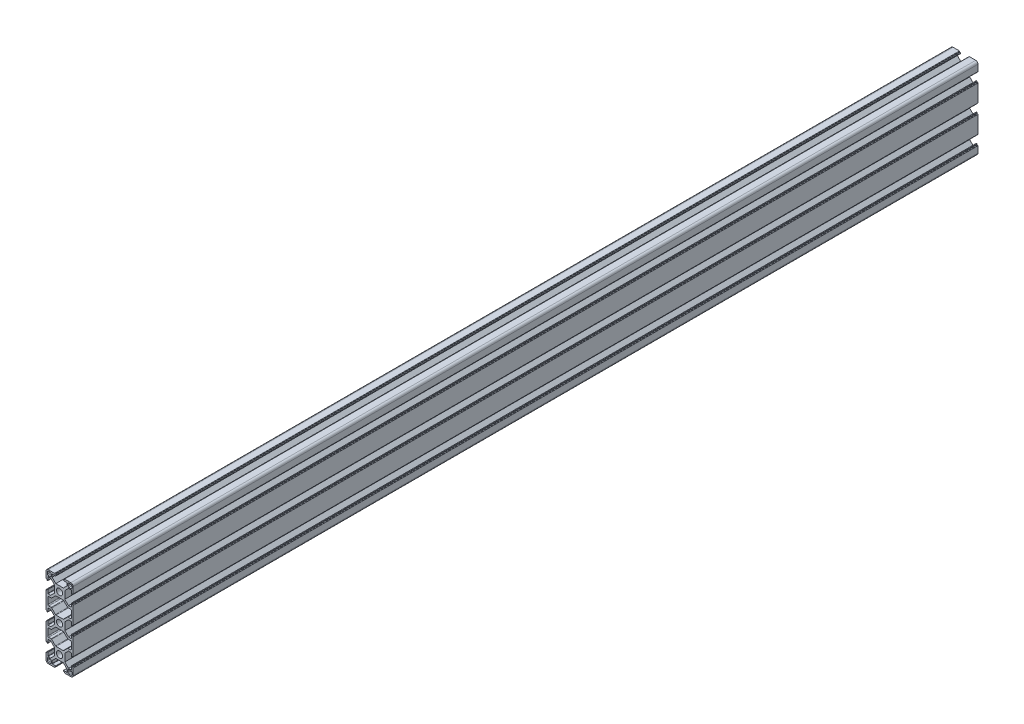
from build123d import *

# Parameters (mm, degrees)
SKETCH_1_R      = 3.4
EXTRUDE_1_DEPTH = 1000


with BuildPart() as part:
    # Эскиз1 → Бобышка-Вытянуть1 (new body)
    with BuildSketch(Plane.XY):
        with BuildLine():
            Line((-15, 8.25), (-15, 12.5))
            ThreePointArc((-15, 12.5), (-14.267766953, 14.267766953), (-12.5, 15))
            Line((-12.5, 15), (-8.25, 15))
            Line((-8.25, 15), (-5.5, 15))
            ThreePointArc((-5.5, 15), (-5.287867966, 14.912132034), (-5.2, 14.7))
            Line((-5.2, 14.7), (-5.2, 14.3))
            ThreePointArc((-5.2, 14.3), (-5.112132034, 14.087867966), (-4.9, 14))
            Line((-4.9, 14), (-4.4, 14))
            ThreePointArc((-4.4, 14), (-4.187867966, 13.912132034), (-4.1, 13.7))
            Line((-4.1, 13.7), (-4.1, 13.3))
            ThreePointArc((-4.1, 13.3), (-4.187867966, 13.087867966), (-4.4, 13))
            Line((-4.4, 13), (-7.95, 13))
            ThreePointArc((-7.95, 13), (-8.162132034, 12.912132034), (-8.25, 12.7))
            Line((-8.25, 12.7), (-8.25, 9.85))
            Line((-8.25, 9.85), (-4.2, 5.8))
            Line((-4.2, 5.8), (4.2, 5.8))
            Line((4.2, 5.8), (8.25, 9.85))
            Line((8.25, 9.85), (8.25, 12.7))
            ThreePointArc((8.25, 12.7), (8.162132034, 12.912132034), (7.95, 13))
            Line((7.95, 13), (4.4, 13))
            ThreePointArc((4.4, 13), (4.187867966, 13.087867966), (4.1, 13.3))
            Line((4.1, 13.3), (4.1, 13.7))
            ThreePointArc((4.1, 13.7), (4.187867966, 13.912132034), (4.4, 14))
            Line((4.4, 14), (4.9, 14))
            ThreePointArc((4.9, 14), (5.112132034, 14.087867966), (5.2, 14.3))
            Line((5.2, 14.3), (5.2, 14.7))
            ThreePointArc((5.2, 14.7), (5.287867966, 14.912132034), (5.5, 15))
            Line((5.5, 15), (8.25, 15))
            Line((8.25, 15), (12.5, 15))
            ThreePointArc((12.5, 15), (14.267766953, 14.267766953), (15, 12.5))
            Line((15, 12.5), (15, 8.25))
            Line((15, 8.25), (15, 5.5))
            ThreePointArc((15, 5.5), (14.912132034, 5.287867966), (14.7, 5.2))
            Line((14.7, 5.2), (14.3, 5.2))
            ThreePointArc((14.3, 5.2), (14.087867966, 5.112132034), (14, 4.9))
            Line((14, 4.9), (14, 4.4))
            ThreePointArc((14, 4.4), (13.912132034, 4.187867966), (13.7, 4.1))
            Line((13.7, 4.1), (13.3, 4.1))
            ThreePointArc((13.3, 4.1), (13.087867966, 4.187867966), (13, 4.4))
            Line((13, 4.4), (13, 7.95))
            ThreePointArc((13, 7.95), (12.912132034, 8.162132034), (12.7, 8.25))
            Line((12.7, 8.25), (9.85, 8.25))
            Line((9.85, 8.25), (5.8, 4.2))
            Line((5.8, 4.2), (5.8, -4.2))
            Line((5.8, -4.2), (9.85, -8.25))
            Line((9.85, -8.25), (12.7, -8.25))
            ThreePointArc((12.7, -8.25), (12.912132034, -8.162132034), (13, -7.95))
            Line((13, -7.95), (13, -4.4))
            ThreePointArc((13, -4.4), (13.087867966, -4.187867966), (13.3, -4.1))
            Line((13.3, -4.1), (13.7, -4.1))
            ThreePointArc((13.7, -4.1), (13.912132034, -4.187867966), (14, -4.4))
            Line((14, -4.4), (14, -4.9))
            ThreePointArc((14, -4.9), (14.087867966, -5.112132034), (14.3, -5.2))
            Line((14.3, -5.2), (14.7, -5.2))
            ThreePointArc((14.7, -5.2), (14.912132034, -5.287867966), (15, -5.5))
            Line((15, -5.5), (15, -8.25))
            Line((15, -8.25), (15, -21.75))
            Line((15, -21.75), (15, -24.5))
            ThreePointArc((15, -24.5), (14.912132034, -24.712132034), (14.7, -24.8))
            Line((14.7, -24.8), (14.3, -24.8))
            ThreePointArc((14.3, -24.8), (14.087867966, -24.887867966), (14, -25.1))
            Line((14, -25.1), (14, -25.6))
            ThreePointArc((14, -25.6), (13.912132034, -25.812132034), (13.7, -25.9))
            Line((13.7, -25.9), (13.3, -25.9))
            ThreePointArc((13.3, -25.9), (13.087867966, -25.812132034), (13, -25.6))
            Line((13, -25.6), (13, -22.05))
            ThreePointArc((13, -22.05), (12.912132034, -21.837867966), (12.7, -21.75))
            Line((12.7, -21.75), (9.85, -21.75))
            Line((9.85, -21.75), (5.8, -25.8))
            Line((5.8, -25.8), (5.8, -34.2))
            Line((5.8, -34.2), (9.85, -38.25))
            Line((9.85, -38.25), (12.7, -38.25))
            ThreePointArc((12.7, -38.25), (12.912132034, -38.162132034), (13, -37.95))
            Line((13, -37.95), (13, -34.4))
            ThreePointArc((13, -34.4), (13.087867966, -34.187867966), (13.3, -34.1))
            Line((13.3, -34.1), (13.7, -34.1))
            ThreePointArc((13.7, -34.1), (13.912132034, -34.187867966), (14, -34.4))
            Line((14, -34.4), (14, -34.9))
            ThreePointArc((14, -34.9), (14.087867966, -35.112132034), (14.3, -35.2))
            Line((14.3, -35.2), (14.7, -35.2))
            ThreePointArc((14.7, -35.2), (14.912132034, -35.287867966), (15, -35.5))
            Line((15, -35.5), (15, -38.25))
            Line((15, -38.25), (15, -51.75))
            Line((15, -51.75), (15, -54.5))
            ThreePointArc((15, -54.5), (14.912132034, -54.712132034), (14.7, -54.8))
            Line((14.7, -54.8), (14.3, -54.8))
            ThreePointArc((14.3, -54.8), (14.087867966, -54.887867966), (14, -55.1))
            Line((14, -55.1), (14, -55.6))
            ThreePointArc((14, -55.6), (13.912132034, -55.812132034), (13.7, -55.9))
            Line((13.7, -55.9), (13.3, -55.9))
            ThreePointArc((13.3, -55.9), (13.087867966, -55.812132034), (13, -55.6))
            Line((13, -55.6), (13, -52.05))
            ThreePointArc((13, -52.05), (12.912132034, -51.837867966), (12.7, -51.75))
            Line((12.7, -51.75), (9.85, -51.75))
            Line((9.85, -51.75), (5.8, -55.8))
            Line((5.8, -55.8), (5.8, -64.2))
            Line((5.8, -64.2), (9.85, -68.25))
            Line((9.85, -68.25), (12.7, -68.25))
            ThreePointArc((12.7, -68.25), (12.912132034, -68.162132034), (13, -67.95))
            Line((13, -67.95), (13, -64.4))
            ThreePointArc((13, -64.4), (13.087867966, -64.187867966), (13.3, -64.1))
            Line((13.3, -64.1), (13.7, -64.1))
            ThreePointArc((13.7, -64.1), (13.912132034, -64.187867966), (14, -64.4))
            Line((14, -64.4), (14, -64.9))
            ThreePointArc((14, -64.9), (14.087867966, -65.112132034), (14.3, -65.2))
            Line((14.3, -65.2), (14.7, -65.2))
            ThreePointArc((14.7, -65.2), (14.912132034, -65.287867966), (15, -65.5))
            Line((15, -65.5), (15, -68.25))
            Line((15, -68.25), (15, -72.5))
            ThreePointArc((15, -72.5), (14.267766953, -74.267766953), (12.5, -75))
            Line((12.5, -75), (8.25, -75))
            Line((8.25, -75), (5.5, -75))
            ThreePointArc((5.5, -75), (5.287867966, -74.912132034), (5.2, -74.7))
            Line((5.2, -74.7), (5.2, -74.3))
            ThreePointArc((5.2, -74.3), (5.112132034, -74.087867966), (4.9, -74))
            Line((4.9, -74), (4.4, -74))
            ThreePointArc((4.4, -74), (4.187867966, -73.912132034), (4.1, -73.7))
            Line((4.1, -73.7), (4.1, -73.3))
            ThreePointArc((4.1, -73.3), (4.187867966, -73.087867966), (4.4, -73))
            Line((4.4, -73), (7.95, -73))
            ThreePointArc((7.95, -73), (8.162132034, -72.912132034), (8.25, -72.7))
            Line((8.25, -72.7), (8.25, -69.85))
            Line((8.25, -69.85), (4.2, -65.8))
            Line((4.2, -65.8), (-4.2, -65.8))
            Line((-4.2, -65.8), (-8.25, -69.85))
            Line((-8.25, -69.85), (-8.25, -72.7))
            ThreePointArc((-8.25, -72.7), (-8.162132034, -72.912132034), (-7.95, -73))
            Line((-7.95, -73), (-4.4, -73))
            ThreePointArc((-4.4, -73), (-4.187867966, -73.087867966), (-4.1, -73.3))
            Line((-4.1, -73.3), (-4.1, -73.7))
            ThreePointArc((-4.1, -73.7), (-4.187867966, -73.912132034), (-4.4, -74))
            Line((-4.4, -74), (-4.9, -74))
            ThreePointArc((-4.9, -74), (-5.112132034, -74.087867966), (-5.2, -74.3))
            Line((-5.2, -74.3), (-5.2, -74.7))
            ThreePointArc((-5.2, -74.7), (-5.287867966, -74.912132034), (-5.5, -75))
            Line((-5.5, -75), (-8.25, -75))
            Line((-8.25, -75), (-12.5, -75))
            ThreePointArc((-12.5, -75), (-14.267766953, -74.267766953), (-15, -72.5))
            Line((-15, -72.5), (-15, -68.25))
            Line((-15, -68.25), (-15, -65.5))
            ThreePointArc((-15, -65.5), (-14.912132034, -65.287867966), (-14.7, -65.2))
            Line((-14.7, -65.2), (-14.3, -65.2))
            ThreePointArc((-14.3, -65.2), (-14.087867966, -65.112132034), (-14, -64.9))
            Line((-14, -64.9), (-14, -64.4))
            ThreePointArc((-14, -64.4), (-13.912132034, -64.187867966), (-13.7, -64.1))
            Line((-13.7, -64.1), (-13.3, -64.1))
            ThreePointArc((-13.3, -64.1), (-13.087867966, -64.187867966), (-13, -64.4))
            Line((-13, -64.4), (-13, -67.95))
            ThreePointArc((-13, -67.95), (-12.912132034, -68.162132034), (-12.7, -68.25))
            Line((-12.7, -68.25), (-9.85, -68.25))
            Line((-9.85, -68.25), (-5.8, -64.2))
            Line((-5.8, -64.2), (-5.8, -55.8))
            Line((-5.8, -55.8), (-9.85, -51.75))
            Line((-9.85, -51.75), (-12.7, -51.75))
            ThreePointArc((-12.7, -51.75), (-12.912132034, -51.837867966), (-13, -52.05))
            Line((-13, -52.05), (-13, -55.6))
            ThreePointArc((-13, -55.6), (-13.087867966, -55.812132034), (-13.3, -55.9))
            Line((-13.3, -55.9), (-13.7, -55.9))
            ThreePointArc((-13.7, -55.9), (-13.912132034, -55.812132034), (-14, -55.6))
            Line((-14, -55.6), (-14, -55.1))
            ThreePointArc((-14, -55.1), (-14.087867966, -54.887867966), (-14.3, -54.8))
            Line((-14.3, -54.8), (-14.7, -54.8))
            ThreePointArc((-14.7, -54.8), (-14.912132034, -54.712132034), (-15, -54.5))
            Line((-15, -54.5), (-15, -51.75))
            Line((-15, -51.75), (-15, -38.25))
            Line((-15, -38.25), (-15, -35.5))
            ThreePointArc((-15, -35.5), (-14.912132034, -35.287867966), (-14.7, -35.2))
            Line((-14.7, -35.2), (-14.3, -35.2))
            ThreePointArc((-14.3, -35.2), (-14.087867966, -35.112132034), (-14, -34.9))
            Line((-14, -34.9), (-14, -34.4))
            ThreePointArc((-14, -34.4), (-13.912132034, -34.187867966), (-13.7, -34.1))
            Line((-13.7, -34.1), (-13.3, -34.1))
            ThreePointArc((-13.3, -34.1), (-13.087867966, -34.187867966), (-13, -34.4))
            Line((-13, -34.4), (-13, -37.95))
            ThreePointArc((-13, -37.95), (-12.912132034, -38.162132034), (-12.7, -38.25))
            Line((-12.7, -38.25), (-9.85, -38.25))
            Line((-9.85, -38.25), (-5.8, -34.2))
            Line((-5.8, -34.2), (-5.8, -25.8))
            Line((-5.8, -25.8), (-9.85, -21.75))
            Line((-9.85, -21.75), (-12.7, -21.75))
            ThreePointArc((-12.7, -21.75), (-12.912132034, -21.837867966), (-13, -22.05))
            Line((-13, -22.05), (-13, -25.6))
            ThreePointArc((-13, -25.6), (-13.087867966, -25.812132034), (-13.3, -25.9))
            Line((-13.3, -25.9), (-13.7, -25.9))
            ThreePointArc((-13.7, -25.9), (-13.912132034, -25.812132034), (-14, -25.6))
            Line((-14, -25.6), (-14, -25.1))
            ThreePointArc((-14, -25.1), (-14.087867966, -24.887867966), (-14.3, -24.8))
            Line((-14.3, -24.8), (-14.7, -24.8))
            ThreePointArc((-14.7, -24.8), (-14.912132034, -24.712132034), (-15, -24.5))
            Line((-15, -24.5), (-15, -21.75))
            Line((-15, -21.75), (-15, -8.25))
            Line((-15, -8.25), (-15, -5.5))
            ThreePointArc((-15, -5.5), (-14.912132034, -5.287867966), (-14.7, -5.2))
            Line((-14.7, -5.2), (-14.3, -5.2))
            ThreePointArc((-14.3, -5.2), (-14.087867966, -5.112132034), (-14, -4.9))
            Line((-14, -4.9), (-14, -4.4))
            ThreePointArc((-14, -4.4), (-13.912132034, -4.187867966), (-13.7, -4.1))
            Line((-13.7, -4.1), (-13.3, -4.1))
            ThreePointArc((-13.3, -4.1), (-13.087867966, -4.187867966), (-13, -4.4))
            Line((-13, -4.4), (-13, -7.95))
            ThreePointArc((-13, -7.95), (-12.912132034, -8.162132034), (-12.7, -8.25))
            Line((-12.7, -8.25), (-9.85, -8.25))
            Line((-9.85, -8.25), (-5.8, -4.2))
            Line((-5.8, -4.2), (-5.8, 4.2))
            Line((-5.8, 4.2), (-9.85, 8.25))
            Line((-9.85, 8.25), (-12.7, 8.25))
            ThreePointArc((-12.7, 8.25), (-12.912132034, 8.162132034), (-13, 7.95))
            Line((-13, 7.95), (-13, 4.4))
            ThreePointArc((-13, 4.4), (-13.087867966, 4.187867966), (-13.3, 4.1))
            Line((-13.3, 4.1), (-13.7, 4.1))
            ThreePointArc((-13.7, 4.1), (-13.912132034, 4.187867966), (-14, 4.4))
            Line((-14, 4.4), (-14, 4.9))
            ThreePointArc((-14, 4.9), (-14.087867966, 5.112132034), (-14.3, 5.2))
            Line((-14.3, 5.2), (-14.7, 5.2))
            ThreePointArc((-14.7, 5.2), (-14.912132034, 5.287867966), (-15, 5.5))
            Line((-15, 5.5), (-15, 8.25))
        make_face()
        Circle(SKETCH_1_R, mode=Mode.SUBTRACT)
        with Locations((0, -30)):
            Circle(SKETCH_1_R, mode=Mode.SUBTRACT)
        with Locations((0, -60)):
            Circle(SKETCH_1_R, mode=Mode.SUBTRACT)
        with BuildLine():
            Line((12.55, 9.35), (10.35, 9.35))
            ThreePointArc((10.35, 9.35), (9.642893219, 9.642893219), (9.35, 10.35))
            Line((9.35, 10.35), (9.35, 12.55))
            ThreePointArc((9.35, 12.55), (9.642893219, 13.257106781), (10.35, 13.55))
            Line((10.35, 13.55), (12.55, 13.55))
            ThreePointArc((12.55, 13.55), (13.257106781, 13.257106781), (13.55, 12.55))
            Line((13.55, 12.55), (13.55, 10.35))
            ThreePointArc((13.55, 10.35), (13.257106781, 9.642893219), (12.55, 9.35))
        make_face(mode=Mode.SUBTRACT)
        with BuildLine():
            Line((-12.55, 13.55), (-10.35, 13.55))
            ThreePointArc((-10.35, 13.55), (-9.642893219, 13.257106781), (-9.35, 12.55))
            Line((-9.35, 12.55), (-9.35, 10.35))
            ThreePointArc((-9.35, 10.35), (-9.642893219, 9.642893219), (-10.35, 9.35))
            Line((-10.35, 9.35), (-12.55, 9.35))
            ThreePointArc((-12.55, 9.35), (-13.257106781, 9.642893219), (-13.55, 10.35))
            Line((-13.55, 10.35), (-13.55, 12.55))
            ThreePointArc((-13.55, 12.55), (-13.257106781, 13.257106781), (-12.55, 13.55))
        make_face(mode=Mode.SUBTRACT)
        with BuildLine():
            Line((-12, -40.5), (-9.402943725, -40.5))
            ThreePointArc((-9.402943725, -40.5), (-9.020260293, -40.423879533), (-8.695836944, -40.207106781))
            Line((-8.695836944, -40.207106781), (-4.581623382, -36.092893219))
            ThreePointArc((-4.581623382, -36.092893219), (-4.257200033, -35.876120467), (-3.8745166, -35.8))
            Line((-3.8745166, -35.8), (3.8745166, -35.8))
            ThreePointArc((3.8745166, -35.8), (4.257200033, -35.876120467), (4.581623382, -36.092893219))
            Line((4.581623382, -36.092893219), (8.695836944, -40.207106781))
            ThreePointArc((8.695836944, -40.207106781), (9.020260293, -40.423879533), (9.402943725, -40.5))
            Line((9.402943725, -40.5), (12, -40.5))
            ThreePointArc((12, -40.5), (12.707106781, -40.792893219), (13, -41.5))
            Line((13, -41.5), (13, -48.5))
            ThreePointArc((13, -48.5), (12.707106781, -49.207106781), (12, -49.5))
            Line((12, -49.5), (9.402943725, -49.5))
            ThreePointArc((9.402943725, -49.5), (9.020260293, -49.576120467), (8.695836944, -49.792893219))
            Line((8.695836944, -49.792893219), (4.581623382, -53.907106781))
            ThreePointArc((4.581623382, -53.907106781), (4.257200033, -54.123879533), (3.8745166, -54.2))
            Line((3.8745166, -54.2), (-3.8745166, -54.2))
            ThreePointArc((-3.8745166, -54.2), (-4.257200033, -54.123879533), (-4.581623382, -53.907106781))
            Line((-4.581623382, -53.907106781), (-8.695836944, -49.792893219))
            ThreePointArc((-8.695836944, -49.792893219), (-9.020260293, -49.576120467), (-9.402943725, -49.5))
            Line((-9.402943725, -49.5), (-12, -49.5))
            ThreePointArc((-12, -49.5), (-12.707106781, -49.207106781), (-13, -48.5))
            Line((-13, -48.5), (-13, -41.5))
            ThreePointArc((-13, -41.5), (-12.707106781, -40.792893219), (-12, -40.5))
        make_face(mode=Mode.SUBTRACT)
        with BuildLine():
            Line((-13, -18.5), (-13, -11.5))
            ThreePointArc((-13, -11.5), (-12.707106781, -10.792893219), (-12, -10.5))
            Line((-12, -10.5), (-9.402943725, -10.5))
            ThreePointArc((-9.402943725, -10.5), (-9.020260293, -10.423879533), (-8.695836944, -10.207106781))
            Line((-8.695836944, -10.207106781), (-4.581623382, -6.092893219))
            ThreePointArc((-4.581623382, -6.092893219), (-4.257200033, -5.876120467), (-3.8745166, -5.8))
            Line((-3.8745166, -5.8), (3.8745166, -5.8))
            ThreePointArc((3.8745166, -5.8), (4.257200033, -5.876120467), (4.581623382, -6.092893219))
            Line((4.581623382, -6.092893219), (8.695836944, -10.207106781))
            ThreePointArc((8.695836944, -10.207106781), (9.020260293, -10.423879533), (9.402943725, -10.5))
            Line((9.402943725, -10.5), (12, -10.5))
            ThreePointArc((12, -10.5), (12.707106781, -10.792893219), (13, -11.5))
            Line((13, -11.5), (13, -18.5))
            ThreePointArc((13, -18.5), (12.707106781, -19.207106781), (12, -19.5))
            Line((12, -19.5), (9.402943725, -19.5))
            ThreePointArc((9.402943725, -19.5), (9.020260293, -19.576120467), (8.695836944, -19.792893219))
            Line((8.695836944, -19.792893219), (4.581623382, -23.907106781))
            ThreePointArc((4.581623382, -23.907106781), (4.257200033, -24.123879533), (3.8745166, -24.2))
            Line((3.8745166, -24.2), (-3.8745166, -24.2))
            ThreePointArc((-3.8745166, -24.2), (-4.257200033, -24.123879533), (-4.581623382, -23.907106781))
            Line((-4.581623382, -23.907106781), (-8.695836944, -19.792893219))
            ThreePointArc((-8.695836944, -19.792893219), (-9.020260293, -19.576120467), (-9.402943725, -19.5))
            Line((-9.402943725, -19.5), (-12, -19.5))
            ThreePointArc((-12, -19.5), (-12.707106781, -19.207106781), (-13, -18.5))
        make_face(mode=Mode.SUBTRACT)
        with BuildLine():
            Line((9.35, -72.55), (9.35, -70.35))
            ThreePointArc((9.35, -70.35), (9.642893219, -69.642893219), (10.35, -69.35))
            Line((10.35, -69.35), (12.55, -69.35))
            ThreePointArc((12.55, -69.35), (13.257106781, -69.642893219), (13.55, -70.35))
            Line((13.55, -70.35), (13.55, -72.55))
            ThreePointArc((13.55, -72.55), (13.257106781, -73.257106781), (12.55, -73.55))
            Line((12.55, -73.55), (10.35, -73.55))
            ThreePointArc((10.35, -73.55), (9.642893219, -73.257106781), (9.35, -72.55))
        make_face(mode=Mode.SUBTRACT)
        with BuildLine():
            Line((-9.35, -72.55), (-9.35, -70.35))
            ThreePointArc((-9.35, -70.35), (-9.642893219, -69.642893219), (-10.35, -69.35))
            Line((-10.35, -69.35), (-12.55, -69.35))
            ThreePointArc((-12.55, -69.35), (-13.257106781, -69.642893219), (-13.55, -70.35))
            Line((-13.55, -70.35), (-13.55, -72.55))
            ThreePointArc((-13.55, -72.55), (-13.257106781, -73.257106781), (-12.55, -73.55))
            Line((-12.55, -73.55), (-10.35, -73.55))
            ThreePointArc((-10.35, -73.55), (-9.642893219, -73.257106781), (-9.35, -72.55))
        make_face(mode=Mode.SUBTRACT)
    extrude(amount=EXTRUDE_1_DEPTH)


solid = part.part
